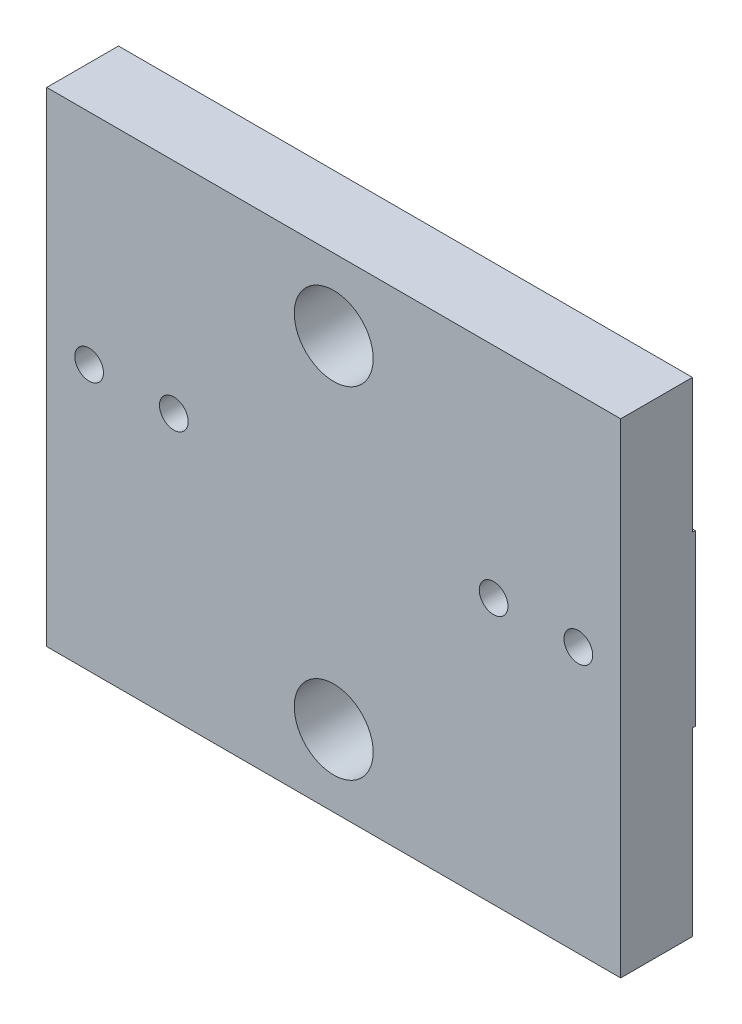
from build123d import *

# Parameters (mm, degrees)
SKETCH1_W         = 20.32
SKETCH1_H         = 17.145
SKETCH1_R         = 1.397
SKETCH1_R_2       = 0.508
BOARD_DEPTH       = 2.54
SKETCH2_W         = 3
SKETCH2_H         = 6
SKETCH2_R         = 0.508
SKETCH2_R_2       = 1.008
SKETCH2_W_2       = 1.5
SKETCH2_H_2       = 0.4
SKETCH2_W_3       = 0.4
SKETCH2_H_3       = 1.389517674
SOLDER_PADS_DEPTH = 0.1


with BuildPart() as part:
    # Sketch1 → Board (new body)
    with BuildSketch(Plane.XY):
        Rectangle(SKETCH1_W, SKETCH1_H)
        with Locations((0, -6.0325)):
            Circle(SKETCH1_R, mode=Mode.SUBTRACT)
        with Locations((0, 6.0325)):
            Circle(SKETCH1_R, mode=Mode.SUBTRACT)
        with Locations((-8.66, 0.8255)):
            Circle(SKETCH1_R_2, mode=Mode.SUBTRACT)
        with Locations((8.66, 0.8255)):
            Circle(SKETCH1_R_2, mode=Mode.SUBTRACT)
        with Locations((-5.66, 0.8255)):
            Circle(SKETCH1_R_2, mode=Mode.SUBTRACT)
        with Locations((5.66, 0.8255)):
            Circle(SKETCH1_R_2, mode=Mode.SUBTRACT)
    extrude(amount=BOARD_DEPTH)

    # Sketch2 → Solder Pads (add)
    with BuildSketch(Plane.XY):
        with Locations((8.66, 0.8255)):
            Rectangle(SKETCH2_W, SKETCH2_H)
        with Locations((8.66, 0.8255)):
            Circle(SKETCH2_R, mode=Mode.SUBTRACT)
        with Locations((-8.66, 0.8255)):
            Rectangle(SKETCH2_W, SKETCH2_H)
        with Locations((-8.66, 0.8255)):
            Circle(SKETCH2_R, mode=Mode.SUBTRACT)
        with Locations((5.66, 0.8255)):
            Circle(SKETCH2_R_2)
        with Locations((5.66, 0.8255)):
            Circle(SKETCH2_R, mode=Mode.SUBTRACT)
        with Locations((-5.66, 0.8255)):
            Circle(SKETCH2_R_2)
        with Locations((-5.66, 0.8255)):
            Circle(SKETCH2_R, mode=Mode.SUBTRACT)
        with Locations((7.91, 4.7255)):
            Rectangle(SKETCH2_W_2, SKETCH2_H_2)
        with Locations((7.91, 4.732624026)):
            Rectangle(SKETCH2_W_3, SKETCH2_H_3)
        with Locations((-7.91, 4.7255)):
            Rectangle(SKETCH2_W_2, SKETCH2_H_2)
    extrude(amount=-SOLDER_PADS_DEPTH)


solid = part.part
